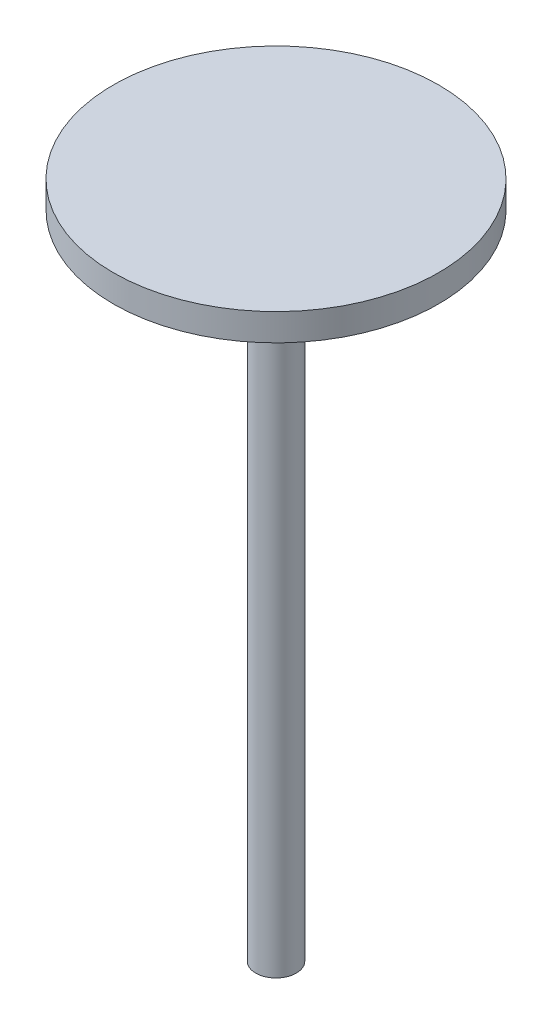
from build123d import *

# Parameters (mm, degrees)
SKETCH1_R           = 9.525
BOSS_EXTRUDE1_DEPTH = 304.8
SKETCH2_R           = 28.2575
BOSS_EXTRUDE2_DEPTH = 6.35
SKETCH3_R           = 76.2
BOSS_EXTRUDE3_DEPTH = 6.35
SKETCH5_R           = 76.2
SKETCH5_R_2         = 70.1675
BOSS_EXTRUDE4_DEPTH = 6.35


with BuildPart() as part:
    # Sketch1 → Boss-Extrude1 (new body)
    with BuildSketch(Plane(origin=(0, 0, 0), x_dir=(1, 0, 0), z_dir=(0, 1, 0))):
        Circle(SKETCH1_R)
    extrude(amount=BOSS_EXTRUDE1_DEPTH)

    # Sketch2 → Boss-Extrude2 (add)
    with BuildSketch(Plane(origin=(0, 304.8, 0), x_dir=(1, 0, 0), z_dir=(0, 1, 0))):
        Circle(SKETCH2_R)
    extrude(amount=BOSS_EXTRUDE2_DEPTH)

    # Sketch3 → Boss-Extrude3 (add)
    with BuildSketch(Plane(origin=(0, 311.15, 0), x_dir=(1, 0, 0), z_dir=(0, 1, 0))):
        Circle(SKETCH3_R)
    extrude(amount=BOSS_EXTRUDE3_DEPTH)

    # Sketch5 → Boss-Extrude4 (add)
    with BuildSketch(Plane.XZ.offset(-311.15)):
        Circle(SKETCH5_R)
        Circle(SKETCH5_R_2, mode=Mode.SUBTRACT)
    extrude(amount=BOSS_EXTRUDE4_DEPTH)


solid = part.part
